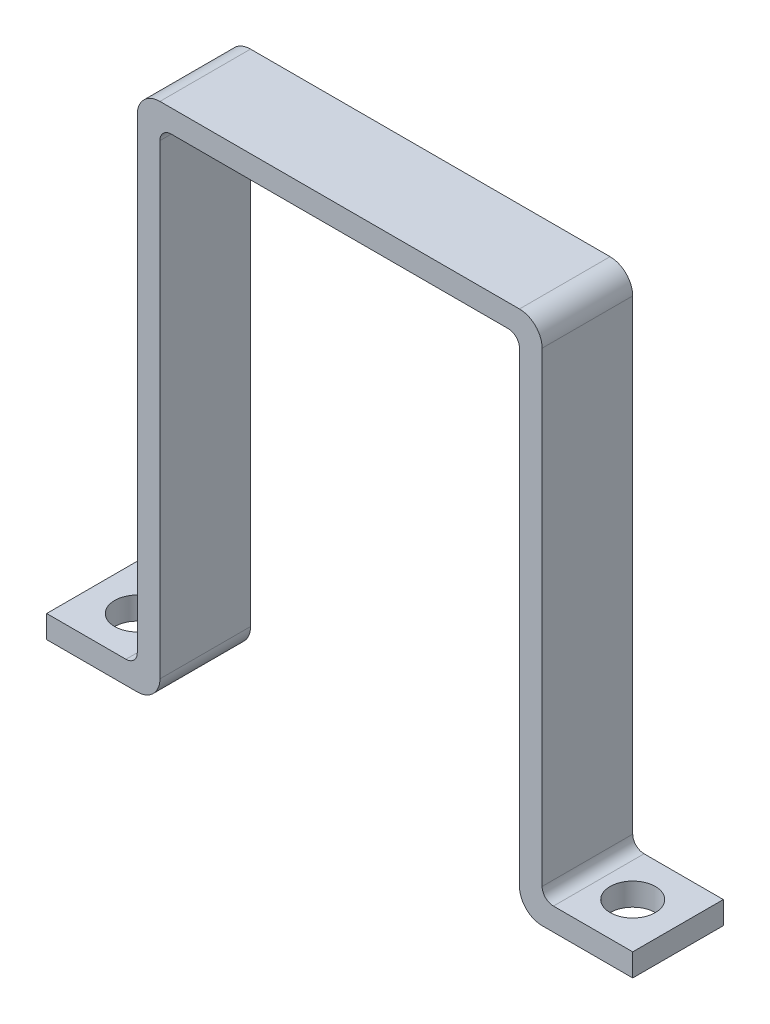
from build123d import *

# Parameters (mm, degrees)
SKETCH1_W             = 15.875
SKETCH1_H             = 12.7
SKETCH1_R             = 3.175
BOSS_EXTRUDE1_DEPTH   = 3.175
BOSS_EXTRUDE1_2_DEPTH = 3.175
SKETCH2_W             = 3.175
SKETCH2_H             = 12.7
BOSS_EXTRUDE2_DEPTH   = 70.104
SKETCH3_W             = 3.175
SKETCH3_H             = 12.7
SKETCH3_W_2           = 53.575
BOSS_EXTRUDE3_DEPTH   = 3.175
FILLET5_R             = 3.175
FILLET6_R             = 1.5875


with BuildPart() as part:
    # Sketch1 → Boss-Extrude1 (new body)
    with BuildSketch(Plane(origin=(0, 0, 0), x_dir=(1, 0, 0), z_dir=(0, 1, 0))):
        with Locations((-1.5875, 0)):
            Rectangle(SKETCH1_W, SKETCH1_H)
        Circle(SKETCH1_R, mode=Mode.SUBTRACT)
    extrude(amount=BOSS_EXTRUDE1_DEPTH)



with BuildPart() as body_2:
    # Sketch1 → Boss-Extrude1 2 (new body)
    with BuildSketch(Plane(origin=(0, 0, 0), x_dir=(1, 0, 0), z_dir=(0, 1, 0))):
        with Locations((-67.8625, 0)):
            Rectangle(SKETCH1_W, SKETCH1_H)
        with Locations((-69.45, 0)):
            Circle(SKETCH1_R, mode=Mode.SUBTRACT)
    extrude(amount=BOSS_EXTRUDE1_2_DEPTH)


with BuildPart() as part_1:
    add(part.part)

    add(body_2.part)  # Boss-Extrude2 merges body 2
    # Sketch2 → Boss-Extrude2 (add)
    with BuildSketch(Plane(origin=(0, 3.175, 0), x_dir=(1, 0, 0), z_dir=(0, 1, 0))):
        with Locations((-61.5125, 0)):
            Rectangle(SKETCH2_W, SKETCH2_H)
        with Locations((-7.9375, 0)):
            Rectangle(SKETCH2_W, SKETCH2_H)
    extrude(amount=BOSS_EXTRUDE2_DEPTH)

    # Sketch3 → Boss-Extrude3 (add)
    with BuildSketch(Plane(origin=(0, 73.279, 0), x_dir=(1, 0, 0), z_dir=(0, 1, 0))):
        with Locations((-61.5125, 0)):
            Rectangle(SKETCH3_W, SKETCH3_H)
        with Locations((-33.1375, 0)):
            Rectangle(SKETCH3_W_2, SKETCH3_H)
    extrude(amount=-BOSS_EXTRUDE3_DEPTH)

    # Fillet5
    fillet5_edges = [part_1.edges().sort_by_distance(p)[0] for p in [
        (-63.1, 73.279, 0),
        (-6.35, 73.279, 0),
        (-9.525, 0, 0),
        (-59.925, 0, 0),
    ]]
    fillet(fillet5_edges, radius=FILLET5_R)

    # Fillet6
    fillet6_edges = [part_1.edges().sort_by_distance(p)[0] for p in [
        (-63.1, 3.175, 0),
        (-59.925, 70.104, 0),
        (-9.525, 70.104, 0),
        (-6.35, 3.175, 0),
    ]]
    fillet(fillet6_edges, radius=FILLET6_R)


solid = part_1.part
